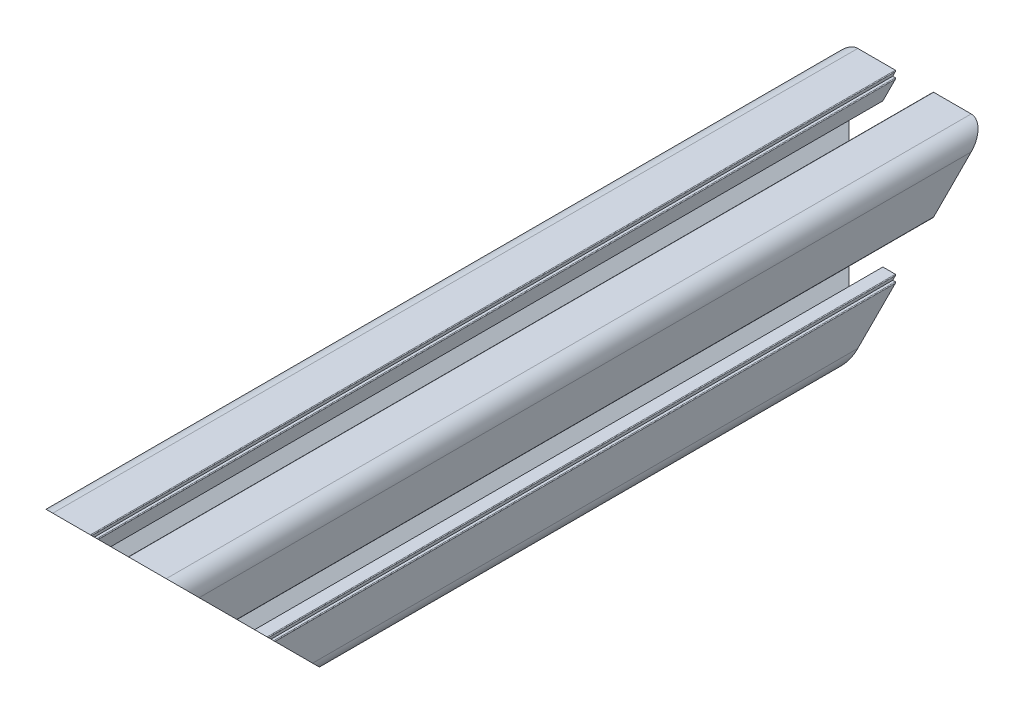
from build123d import *

# Parameters (mm, degrees)
SKETCH_1_R          = 2.95
SKETCH_1_R_2        = 3.4
EXTRUDE_1_DEPTH     = 110
CUT_EXTRUDE_1_DEPTH = 86


with BuildPart() as part:
    # 草图1 → 凸台-拉伸1 (new body, symmetric)
    with BuildSketch(Plane.XY.offset(50)):
        with BuildLine():
            Line((-1518.245004392, 3588.004280474), (-1518.245004392, 3582.975600817))
            Line((-1518.245004392, 3582.975600817), (-1522.916324736, 3578.304280474))
            Line((-1522.916324736, 3578.304280474), (-1533.673684048, 3578.304280474))
            Line((-1533.673684048, 3578.304280474), (-1538.345004392, 3582.975600817))
            Line((-1538.345004392, 3582.975600817), (-1538.345004392, 3588.004280474))
            Line((-1538.345004392, 3588.004280474), (-1534.845004392, 3588.004280474))
            Line((-1534.845004392, 3588.004280474), (-1534.845004392, 3586.304280474))
            Line((-1534.845004392, 3586.304280474), (-1532.445004392, 3586.304280474))
            Line((-1532.445004392, 3586.304280474), (-1532.445004392, 3589.704280474))
            ThreePointArc((-1532.445004392, 3589.704280474), (-1532.503583036, 3589.84570183), (-1532.645004392, 3589.904280474))
            Line((-1532.645004392, 3589.904280474), (-1533.345004392, 3589.904280474))
            Line((-1533.345004392, 3589.904280474), (-1533.345004392, 3590.604280474))
            ThreePointArc((-1533.345004392, 3590.604280474), (-1533.403583036, 3590.74570183), (-1533.545004392, 3590.804280474))
            Line((-1533.545004392, 3590.804280474), (-1543.795004392, 3590.804280474))
            ThreePointArc((-1543.795004392, 3590.804280474), (-1546.976984907, 3589.486260989), (-1548.295004392, 3586.304280474))
            Line((-1548.295004392, 3586.304280474), (-1548.295004392, 3576.054280474))
            ThreePointArc((-1548.295004392, 3576.054280474), (-1548.236425748, 3575.912859117), (-1548.095004392, 3575.854280474))
            Line((-1548.095004392, 3575.854280474), (-1547.395004392, 3575.854280474))
            Line((-1547.395004392, 3575.854280474), (-1547.395004392, 3575.154280474))
            ThreePointArc((-1547.395004392, 3575.154280474), (-1547.336425748, 3575.012859117), (-1547.195004392, 3574.954280474))
            Line((-1547.195004392, 3574.954280474), (-1543.795004392, 3574.954280474))
            Line((-1543.795004392, 3574.954280474), (-1543.795004392, 3577.354280474))
            Line((-1543.795004392, 3577.354280474), (-1545.495004392, 3577.354280474))
            Line((-1545.495004392, 3577.354280474), (-1545.495004392, 3580.854280474))
            Line((-1545.495004392, 3580.854280474), (-1540.466324736, 3580.854280474))
            Line((-1540.466324736, 3580.854280474), (-1535.795004392, 3576.18296013))
            Line((-1535.795004392, 3576.18296013), (-1535.795004392, 3565.425600817))
            Line((-1535.795004392, 3565.425600817), (-1540.466324736, 3560.754280474))
            Line((-1540.466324736, 3560.754280474), (-1545.495004392, 3560.754280474))
            Line((-1545.495004392, 3560.754280474), (-1545.495004392, 3564.254280474))
            Line((-1545.495004392, 3564.254280474), (-1543.795004392, 3564.254280474))
            Line((-1543.795004392, 3564.254280474), (-1543.795004392, 3566.654280474))
            Line((-1543.795004392, 3566.654280474), (-1547.195004392, 3566.654280474))
            ThreePointArc((-1547.195004392, 3566.654280474), (-1547.336425748, 3566.59570183), (-1547.395004392, 3566.454280474))
            Line((-1547.395004392, 3566.454280474), (-1547.395004392, 3565.754280474))
            Line((-1547.395004392, 3565.754280474), (-1548.095004392, 3565.754280474))
            ThreePointArc((-1548.095004392, 3565.754280474), (-1548.236425748, 3565.69570183), (-1548.295004392, 3565.554280474))
            Line((-1548.295004392, 3565.554280474), (-1548.295004392, 3555.304280474))
            ThreePointArc((-1548.295004392, 3555.304280474), (-1546.976984907, 3552.122299958), (-1543.795004392, 3550.804280474))
            Line((-1543.795004392, 3550.804280474), (-1533.545004392, 3550.804280474))
            ThreePointArc((-1533.545004392, 3550.804280474), (-1533.403583036, 3550.862859117), (-1533.345004392, 3551.004280474))
            Line((-1533.345004392, 3551.004280474), (-1533.345004392, 3551.704280474))
            Line((-1533.345004392, 3551.704280474), (-1532.645004392, 3551.704280474))
            ThreePointArc((-1532.645004392, 3551.704280474), (-1532.503583036, 3551.762859117), (-1532.445004392, 3551.904280474))
            Line((-1532.445004392, 3551.904280474), (-1532.445004392, 3555.304280474))
            Line((-1532.445004392, 3555.304280474), (-1534.845004392, 3555.304280474))
            Line((-1534.845004392, 3555.304280474), (-1534.845004392, 3553.604280474))
            Line((-1534.845004392, 3553.604280474), (-1538.345004392, 3553.604280474))
            Line((-1538.345004392, 3553.604280474), (-1538.345004392, 3558.63296013))
            Line((-1538.345004392, 3558.63296013), (-1533.673684048, 3563.304280474))
            Line((-1533.673684048, 3563.304280474), (-1522.916324736, 3563.304280474))
            Line((-1522.916324736, 3563.304280474), (-1518.245004392, 3558.63296013))
            Line((-1518.245004392, 3558.63296013), (-1518.245004392, 3553.604280474))
            Line((-1518.245004392, 3553.604280474), (-1521.745004392, 3553.604280474))
            Line((-1521.745004392, 3553.604280474), (-1521.745004392, 3555.304280474))
            Line((-1521.745004392, 3555.304280474), (-1524.145004392, 3555.304280474))
            Line((-1524.145004392, 3555.304280474), (-1524.145004392, 3551.904280474))
            ThreePointArc((-1524.145004392, 3551.904280474), (-1524.086425748, 3551.762859117), (-1523.945004392, 3551.704280474))
            Line((-1523.945004392, 3551.704280474), (-1523.245004392, 3551.704280474))
            Line((-1523.245004392, 3551.704280474), (-1523.245004392, 3551.004280474))
            ThreePointArc((-1523.245004392, 3551.004280474), (-1523.186425748, 3550.862859117), (-1523.045004392, 3550.804280474))
            Line((-1523.045004392, 3550.804280474), (-1512.795004392, 3550.804280474))
            ThreePointArc((-1512.795004392, 3550.804280474), (-1509.613023877, 3552.122299958), (-1508.295004392, 3555.304280474))
            Line((-1508.295004392, 3555.304280474), (-1508.295004392, 3565.554280474))
            ThreePointArc((-1508.295004392, 3565.554280474), (-1508.353583036, 3565.69570183), (-1508.495004392, 3565.754280474))
            Line((-1508.495004392, 3565.754280474), (-1509.195004392, 3565.754280474))
            Line((-1509.195004392, 3565.754280474), (-1509.195004392, 3566.454280474))
            ThreePointArc((-1509.195004392, 3566.454280474), (-1509.253583036, 3566.59570183), (-1509.395004392, 3566.654280474))
            Line((-1509.395004392, 3566.654280474), (-1512.795004392, 3566.654280474))
            Line((-1512.795004392, 3566.654280474), (-1512.795004392, 3564.254280474))
            Line((-1512.795004392, 3564.254280474), (-1511.095004392, 3564.254280474))
            Line((-1511.095004392, 3564.254280474), (-1511.095004392, 3560.754280474))
            Line((-1511.095004392, 3560.754280474), (-1516.123684048, 3560.754280474))
            Line((-1516.123684048, 3560.754280474), (-1520.795004392, 3565.425600817))
            Line((-1520.795004392, 3565.425600817), (-1520.795004392, 3576.18296013))
            Line((-1520.795004392, 3576.18296013), (-1516.123684048, 3580.854280474))
            Line((-1516.123684048, 3580.854280474), (-1511.095004392, 3580.854280474))
            Line((-1511.095004392, 3580.854280474), (-1511.095004392, 3577.354280474))
            Line((-1511.095004392, 3577.354280474), (-1512.795004392, 3577.354280474))
            Line((-1512.795004392, 3577.354280474), (-1512.795004392, 3574.954280474))
            Line((-1512.795004392, 3574.954280474), (-1509.395004392, 3574.954280474))
            ThreePointArc((-1509.395004392, 3574.954280474), (-1509.253583036, 3575.012859117), (-1509.195004392, 3575.154280474))
            Line((-1509.195004392, 3575.154280474), (-1509.195004392, 3575.854280474))
            Line((-1509.195004392, 3575.854280474), (-1508.495004392, 3575.854280474))
            ThreePointArc((-1508.495004392, 3575.854280474), (-1508.353583036, 3575.912859117), (-1508.295004392, 3576.054280474))
            Line((-1508.295004392, 3576.054280474), (-1508.295004392, 3586.304280474))
            ThreePointArc((-1508.295004392, 3586.304280474), (-1509.613023877, 3589.486260989), (-1512.795004392, 3590.804280474))
            Line((-1512.795004392, 3590.804280474), (-1523.045004392, 3590.804280474))
            ThreePointArc((-1523.045004392, 3590.804280474), (-1523.186425748, 3590.74570183), (-1523.245004392, 3590.604280474))
            Line((-1523.245004392, 3590.604280474), (-1523.245004392, 3589.904280474))
            Line((-1523.245004392, 3589.904280474), (-1523.945004392, 3589.904280474))
            ThreePointArc((-1523.945004392, 3589.904280474), (-1524.086425748, 3589.84570183), (-1524.145004392, 3589.704280474))
            Line((-1524.145004392, 3589.704280474), (-1524.145004392, 3586.304280474))
            Line((-1524.145004392, 3586.304280474), (-1521.745004392, 3586.304280474))
            Line((-1521.745004392, 3586.304280474), (-1521.745004392, 3588.004280474))
            Line((-1521.745004392, 3588.004280474), (-1518.245004392, 3588.004280474))
        make_face()
        with Locations((-1513.270004392, 3555.779280474)):
            Circle(SKETCH_1_R, mode=Mode.SUBTRACT)
        with Locations((-1528.295004392, 3570.804280474)):
            Circle(SKETCH_1_R_2, mode=Mode.SUBTRACT)
        with Locations((-1513.270004392, 3585.829280474)):
            Circle(SKETCH_1_R, mode=Mode.SUBTRACT)
        with Locations((-1543.320004392, 3585.829280474)):
            Circle(SKETCH_1_R, mode=Mode.SUBTRACT)
        with Locations((-1543.320004392, 3555.779280474)):
            Circle(SKETCH_1_R, mode=Mode.SUBTRACT)
    extrude(amount=EXTRUDE_1_DEPTH, both=True)

    # 草图2 → 切除-拉伸1 (cut)
    with BuildSketch(Plane(origin=(-1508.295004392, 0, 0), x_dir=(0, 0, -1), z_dir=(1, 0, 0))):
        Polygon((60, 3590.804280474), (60, 3550.804280474), (20, 3550.804280474), align=None)
        Polygon((-160, 3590.804280474), (-160, 3550.804280474), (-120, 3550.804280474), align=None)
    extrude(amount=-CUT_EXTRUDE_1_DEPTH, mode=Mode.SUBTRACT)


solid = part.part
